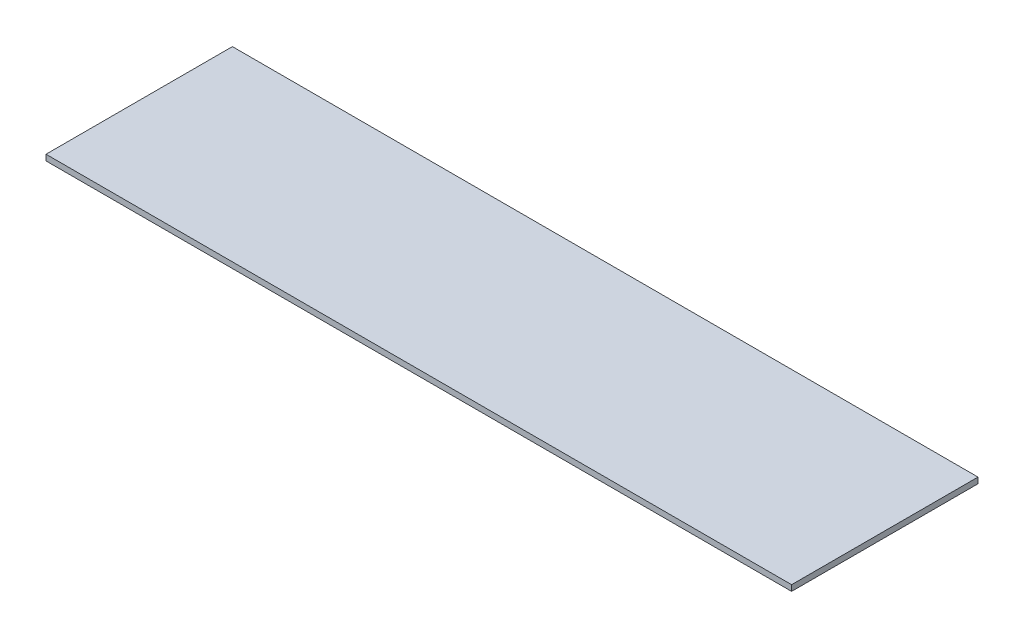
from build123d import *

# Parameters (mm, degrees)
SKETCH1_W           = 406.4
SKETCH1_H           = 101.6
BOSS_EXTRUDE1_DEPTH = 3.175


with BuildPart() as part:
    # Sketch1 → Boss-Extrude1 (new body)
    with BuildSketch(Plane.XZ.offset(80.26236602)):
        with Locations((203.2, 50.8)):
            Rectangle(SKETCH1_W, SKETCH1_H)
    extrude(amount=BOSS_EXTRUDE1_DEPTH)


solid = part.part
